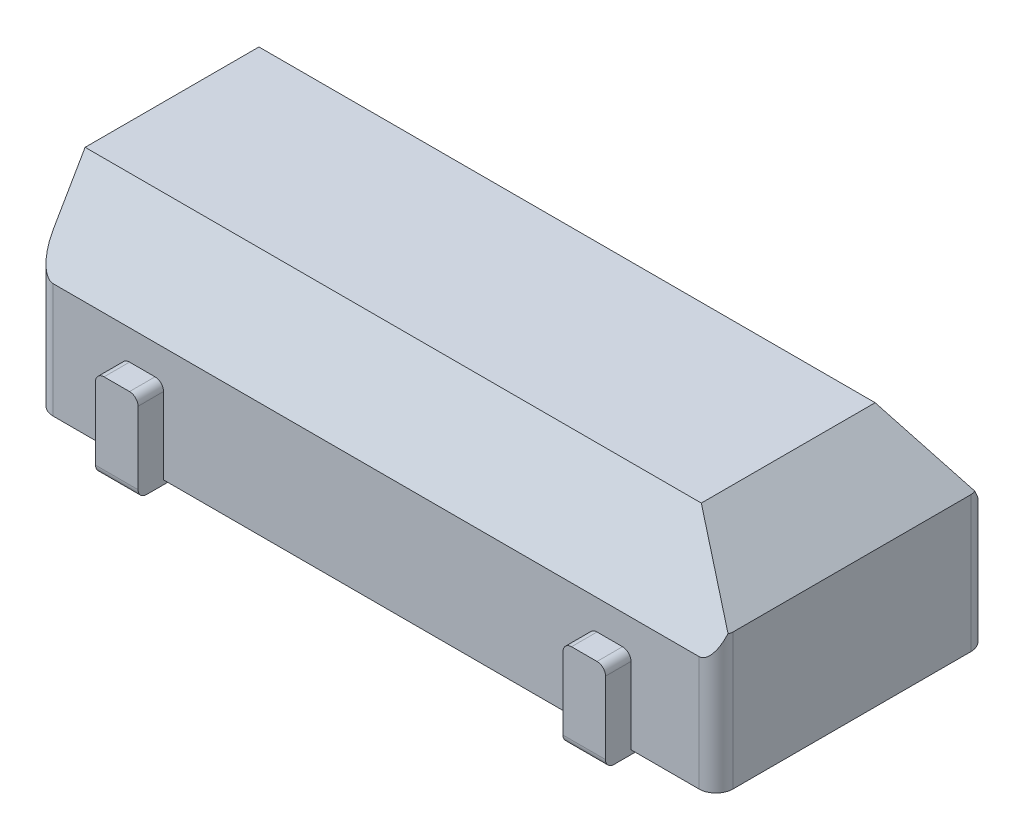
from build123d import *

# Parameters (mm, degrees)
SKETCH_1_W             = 8
SKETCH_1_H             = 3.2
EXTRUDE_1_DEPTH        = 2.35
SKETCH_2_W             = 0.5
SKETCH_2_H             = 0.6
EXTRUDE_2_DEPTH        = 0.05
EXTRUDE_2_DEPTH_BACK   = 1
FILLET_1_R             = 0.1
CHAMFER_1_SIZE         = 1
CHAMFER_1_SIZE2        = 0.577350269
CHAMFER_1_PART_2_SIZE  = 1
CHAMFER_1_PART_2_SIZE2 = 0.577350269
CHAMFER_2_SIZE         = 0.75
FILLET_2_R             = 0.2


with BuildPart() as part:
    # Эскиз1 → Бобышка-Вытянуть1 (new body)
    with BuildSketch(Plane(origin=(0, 0, 0), x_dir=(1, 0, 0), z_dir=(0, 1, 0))):
        Rectangle(SKETCH_1_W, SKETCH_1_H)
    extrude(amount=EXTRUDE_1_DEPTH)

    # Эскиз2 → Бобышка-Вытянуть2 (add, two sides)
    with BuildSketch(Plane.XZ) as extrude_2_sk:
        with Locations((-2.75, 1.6)):
            Rectangle(SKETCH_2_W, SKETCH_2_H)
        with Locations((2.75, 1.6)):
            Rectangle(SKETCH_2_W, SKETCH_2_H)
        with Locations((2.75, -1.6)):
            Rectangle(SKETCH_2_W, SKETCH_2_H)
        with Locations((-2.75, -1.6)):
            Rectangle(SKETCH_2_W, SKETCH_2_H)
    extrude(amount=EXTRUDE_2_DEPTH)
    extrude(extrude_2_sk.sketch, amount=-EXTRUDE_2_DEPTH_BACK)

    # Скругление1
    fillet_1_edges = [part.edges().sort_by_distance(p)[0] for p in [
        (-2.5, 1, 1.75),
        (-3, 1, 1.75),
        (-2.75, -0.05, 1.9),
        (3, 1, 1.75),
        (2.5, 1, 1.75),
        (2.75, -0.05, 1.9),
        (3, 1, -1.75),
        (2.5, 1, -1.75),
        (2.75, -0.05, -1.9),
        (-3, 1, -1.75),
        (-2.5, 1, -1.75),
        (-2.75, -0.05, -1.9),
    ]]
    fillet(fillet_1_edges, radius=FILLET_1_R)

    # Фаска1
    chamfer_1_edges = [part.edges().sort_by_distance(p)[0] for p in [
        (0, 2.35, 1.6),
    ]]
    chamfer_1_side = [part.faces().sort_by_distance(p)[0] for p in [
        (0, 1.212807949, 1.6),
    ]]
    chamfer(chamfer_1_edges, length=CHAMFER_1_SIZE, length2=CHAMFER_1_SIZE2, reference=chamfer_1_side[0])

    # Фаска1 part 2
    chamfer_1_part_2_edges = [part.edges().sort_by_distance(p)[0] for p in [
        (0, 2.35, -1.6),
    ]]
    chamfer_1_part_2_side = [part.faces().sort_by_distance(p)[0] for p in [
        (0, 1.212807949, -1.6),
    ]]
    chamfer(chamfer_1_part_2_edges, length=CHAMFER_1_PART_2_SIZE, length2=CHAMFER_1_PART_2_SIZE2, reference=chamfer_1_part_2_side[0])

    # Фаска2
    chamfer_2_edges = [part.edges().sort_by_distance(p)[0] for p in [
        (4, 2.35, 0),
    ]]
    chamfer(chamfer_2_edges, length=CHAMFER_2_SIZE)

    # Скругление2
    fillet_2_edges = [part.edges().sort_by_distance(p)[0] for p in [
        (-4, 0.675, 1.6),
        (-4, 0.675, -1.6),
        (4, 0.675, 1.6),
        (4, 0.675, -1.6),
    ]]
    fillet(fillet_2_edges, radius=FILLET_2_R)


solid = part.part
